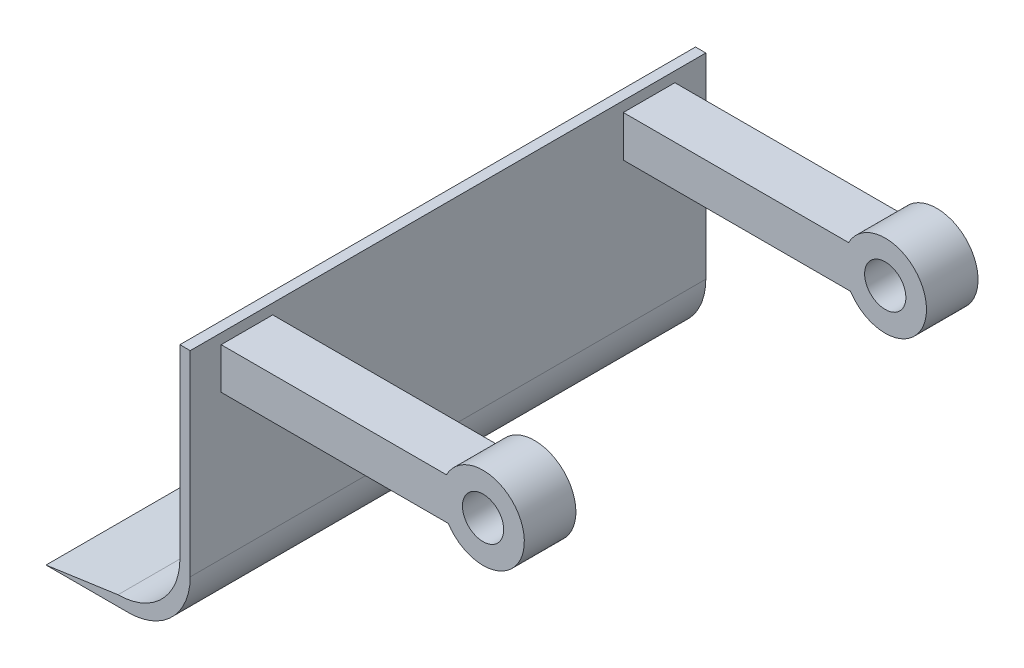
from build123d import *

# Parameters (mm, degrees)
BOSS_EXTRU_1_DEPTH      = 250
ESQUISSE3_W             = 25
ESQUISSE3_H             = 20
BOSS_EXTRU_2_DEPTH      = 125
ESQUISSE4_R             = 20
BOSS_EXTRU_3_DEPTH      = 25
ESQUISSE5_R             = 20
BOSS_EXTRU_4_DEPTH      = 25
ESQUISSE6_R             = 10
ENL_V_MAT_EXTRU_1_DEPTH = 236


with BuildPart() as part:
    # Esquisse1 → Boss.-Extru.1 (new body)
    with BuildSketch(Plane.XY):
        with BuildLine():
            Line((-30, 0), (-69.925793841, 0))
            Line((-69.925793841, 0), (-35, 5))
            ThreePointArc((-35, 5), (-13.786796564, 13.786796564), (-5, 35))
            Line((-5, 35), (-5, 125))
            Line((-5, 125), (0, 125))
            Line((0, 125), (0, 30))
            ThreePointArc((0, 30), (-8.786796564, 8.786796564), (-30, 0))
        make_face()
    extrude(amount=BOSS_EXTRU_1_DEPTH)

    # Esquisse3 → Boss.-Extru.2 (add)
    with BuildSketch(Plane(origin=(0, 0, 0), x_dir=(0, 0, -1), z_dir=(1, 0, 0))):
        with Locations((-222.5, 110)):
            Rectangle(ESQUISSE3_W, ESQUISSE3_H)
        with Locations((-27.5, 110)):
            Rectangle(ESQUISSE3_W, ESQUISSE3_H)
    extrude(amount=BOSS_EXTRU_2_DEPTH)

    # Esquisse4 → Boss.-Extru.3 (add)
    with BuildSketch(Plane.XY.offset(235)):
        with Locations((127, 110.778032317)):
            Circle(ESQUISSE4_R)
    extrude(amount=-BOSS_EXTRU_3_DEPTH)

    # Esquisse5 → Boss.-Extru.4 (add)
    with BuildSketch(Plane.XY.offset(40)):
        with Locations((127, 110.778032317)):
            Circle(ESQUISSE5_R)
    extrude(amount=-BOSS_EXTRU_4_DEPTH)

    # Esquisse6 → Enlèv. mat.-Extru.1 (cut, through all)
    with BuildSketch(Plane.XY.offset(235)):
        with Locations((127, 110.778032317)):
            Circle(ESQUISSE6_R)
    extrude(amount=-ENL_V_MAT_EXTRU_1_DEPTH, mode=Mode.SUBTRACT)


solid = part.part
